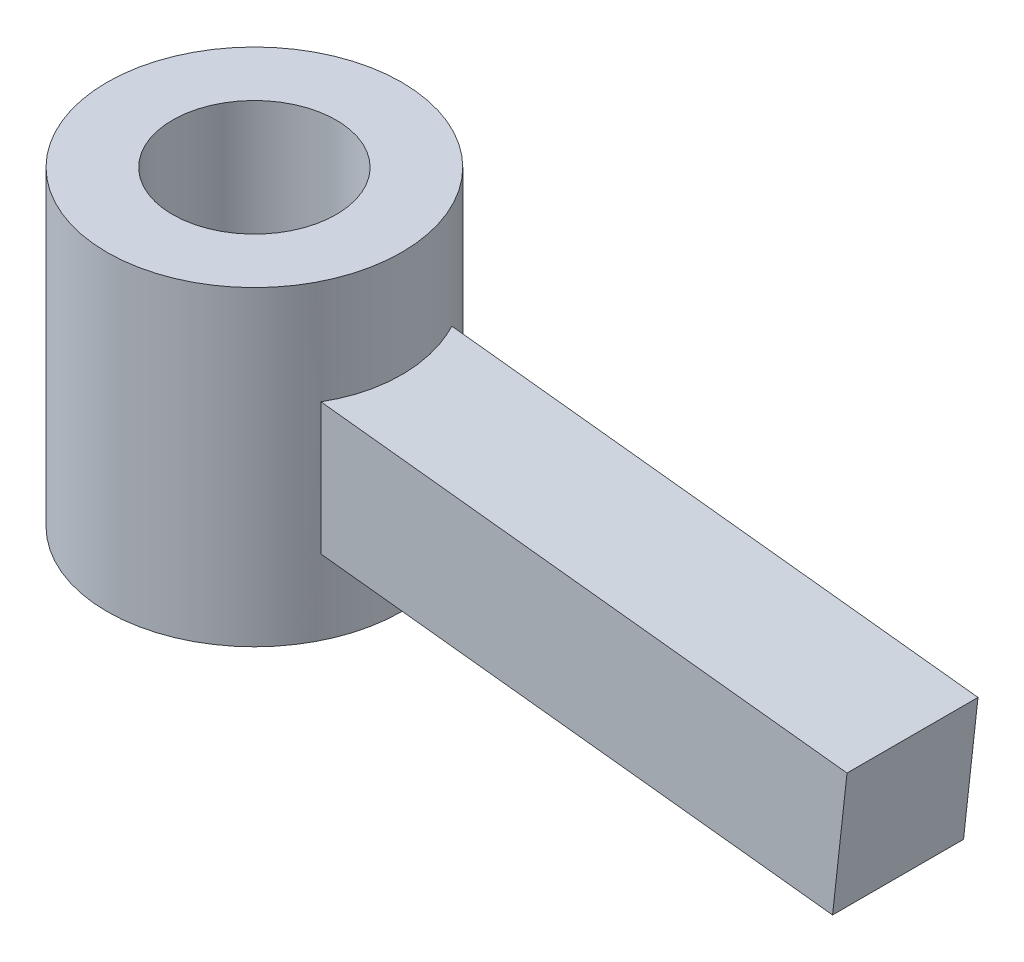
from build123d import *

# Parameters (mm, degrees)
CUT_EXTRUDE1_DEPTH       = 10.898670365
CUT_EXTRUDE1_DEPTH_BACK  = 10.898670365
SKETCH2_R                = 3.175
BOSS_EXTRUDE1_DEPTH      = 6.0325
BOSS_EXTRUDE1_DEPTH_BACK = 6.0325
SKETCH3_R                = 5.715
SKETCH3_R_2              = 3.175
SKETCH4_W                = 5.08
SKETCH4_H                = 5.08
BOSS_EXTRUDE2_DEPTH      = 25.4


with BuildPart() as part:
    # Sketch1 → Revolve1 (revolve)
    with BuildSketch(Plane.XY):
        with BuildLine():
            Line((0, 5.715), (0, -5.715))
            ThreePointArc((0, -5.715), (5.715, 0), (0, 5.715))
        make_face()
    revolve(axis=Axis((0, 5.715, 0), (0, -1, 0)))

    # Sketch2 → Cut-Extrude1 (cut, two sides: drawn at the far end of the back side and taken through both)
    with BuildSketch(Plane(origin=(0, 0, 0), x_dir=(1, 0, 0), z_dir=(0, 1, 0)).offset(-CUT_EXTRUDE1_DEPTH_BACK)):
        Circle(SKETCH2_R)
    extrude(amount=CUT_EXTRUDE1_DEPTH + CUT_EXTRUDE1_DEPTH_BACK, mode=Mode.SUBTRACT)

    # Sketch3 → Boss-Extrude1 (add, two sides: drawn at the far end of the back side and taken through both)
    with BuildSketch(Plane(origin=(0, 0, 0), x_dir=(1, 0, 0), z_dir=(0, 1, 0)).offset(-BOSS_EXTRUDE1_DEPTH_BACK)):
        Circle(SKETCH3_R)
        Circle(SKETCH3_R_2, mode=Mode.SUBTRACT)
    extrude(amount=BOSS_EXTRUDE1_DEPTH + BOSS_EXTRUDE1_DEPTH_BACK)

    # Sketch4 → Boss-Extrude2 (add)
    with BuildSketch(Plane(origin=(0, 0, 0), x_dir=(0, 0, -1), z_dir=(-0.9938841042379178, 0.11042819994544796, 0))):
        Rectangle(SKETCH4_W, SKETCH4_H)
    extrude(amount=-BOSS_EXTRUDE2_DEPTH)


solid = part.part
